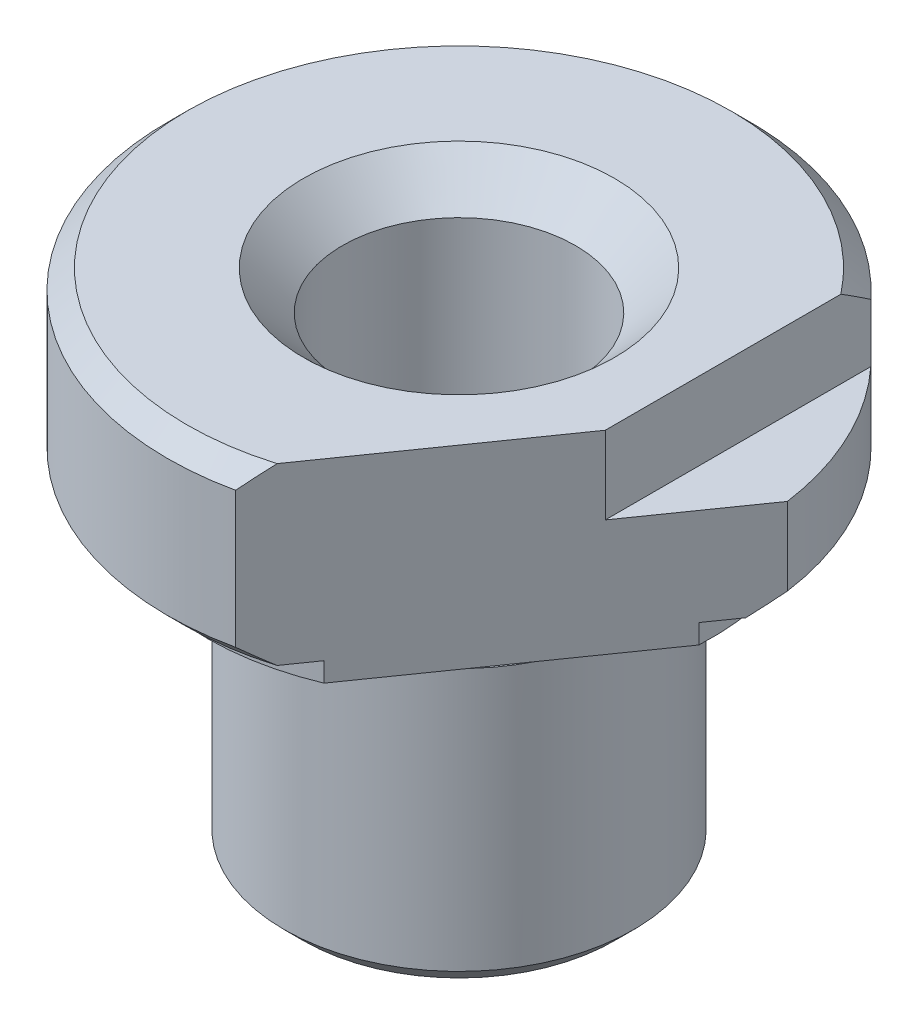
from build123d import *

# Parameters (mm, degrees)
SKETCH_2_R          = 6
CUT_EXTRUDE_1_DEPTH = 27
CUT_EXTRUDE_2_DEPTH = 4
CHAMFER_2_SIZE      = 2
CHAMFER_3_SIZE      = 1
CHAMFER_4_SIZE      = 0.5
CUT_EXTRUDE_3_DEPTH = 10


with BuildPart() as part:
    # 草图1 → 旋转1 (revolve)
    with BuildSketch(Plane.XY):
        Polygon((0, 0), (9, 0), (9, 15), (8, 15), (8, 16), (8, 16.5), (10, 16.5), (10, 16), (13, 16), (13, 17), (15, 17), (15, 26), (0, 26), align=None)
    revolve(axis=Axis((0, 26, 0), (0, -1, 0)))

    # 草图2 → 切除-拉伸1 (cut, through all)
    with BuildSketch(Plane.XZ):
        Circle(SKETCH_2_R)
    extrude(amount=-CUT_EXTRUDE_1_DEPTH, mode=Mode.SUBTRACT)

    # 草图3 → 切除-拉伸2 (cut)
    with BuildSketch(Plane(origin=(0, 26, 0), x_dir=(1, 0, 0), z_dir=(0, 1, 0))):
        with BuildLine():
            Line((11, 10.198039027), (11, -10.198039027))
            ThreePointArc((11, -10.198039027), (15, 0), (11, 10.198039027))
        make_face()
    extrude(amount=-CUT_EXTRUDE_2_DEPTH, mode=Mode.SUBTRACT)

    # 倒角2
    chamfer_2_edges = [part.edges().sort_by_distance(p)[0] for p in [
        (-6, 26, 0),
    ]]
    chamfer(chamfer_2_edges, length=CHAMFER_2_SIZE)

    # 倒角3
    chamfer_3_edges = [part.edges().sort_by_distance(p)[0] for p in [
        (-9, 0, 0),
        (-15, 17, 0),
        (-15, 26, 0),
    ]]
    chamfer(chamfer_3_edges, length=CHAMFER_3_SIZE)

    # 倒角4
    chamfer_4_edges = [part.edges().sort_by_distance(p)[0] for p in [
        (-9, 15, 0),
        (-6, 0, 0),
    ]]
    chamfer(chamfer_4_edges, length=CHAMFER_4_SIZE)

    # 草图4 → 切除-拉伸3 (cut)
    with BuildSketch(Plane(origin=(0, 26, 0), x_dir=(1, 0, 0), z_dir=(0, 1, 0))):
        with BuildLine():
            Line((3.161317604, -14.663085317), (14.86002737, 2.044403717))
            ThreePointArc((14.86002737, 2.044403717), (14.305754261, -4.510586993), (11, -10.198039027))
            ThreePointArc((11, -10.198039027), (7.424276979, -13.033806479), (3.161317604, -14.663085317))
        make_face()
    extrude(amount=-CUT_EXTRUDE_3_DEPTH, mode=Mode.SUBTRACT)


solid = part.part
